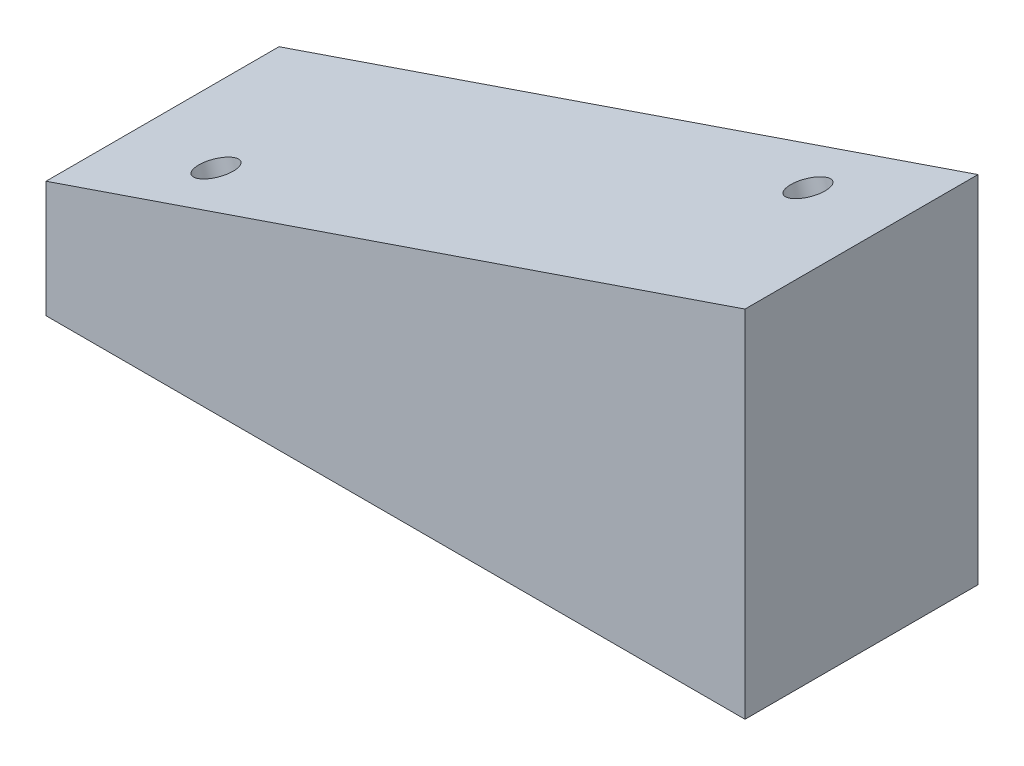
from build123d import *

# Parameters (mm, degrees)
BOSS_EXTRUDE1_DEPTH         = 50.8
F_3_8_16_TAPPED_HOLE1_D     = 7.9375
F_3_8_16_TAPPED_HOLE1_DEPTH = 25.4
F_3_8_16_TAPPED_HOLE1_TIP   = 2.384665582
F_3_8_16_TAPPED_HOLE2_D     = 7.9375
F_3_8_16_TAPPED_HOLE2_DEPTH = 25.4
F_3_8_16_TAPPED_HOLE2_TIP   = 2.384665582


with BuildPart() as part:
    # Sketch1 → Boss-Extrude1 (new body)
    with BuildSketch(Plane.XY):
        Polygon((-76.2, 0), (76.2, 0), (76.2, 77.459343803), (-76.2, 25.4), align=None)
    extrude(amount=-BOSS_EXTRUDE1_DEPTH)

    # 3/8-16 Tapped Hole1
    with Locations(Plane(origin=(-15.732418717, 46.055528891, 0), x_dir=(0.946311265, 0.323256847, 0), z_dir=(-0.323256847, 0.946311265, 0))):
        with Locations((-38.143756412, 12.7), (71.393743588, 38.1)):
            Hole(F_3_8_16_TAPPED_HOLE1_D / 2, depth=F_3_8_16_TAPPED_HOLE1_DEPTH)
            with Locations((0, 0, -(F_3_8_16_TAPPED_HOLE1_DEPTH + F_3_8_16_TAPPED_HOLE1_TIP / 2))):  # 118° drill point
                Cone(0, F_3_8_16_TAPPED_HOLE1_D / 2, F_3_8_16_TAPPED_HOLE1_TIP, mode=Mode.SUBTRACT)

    # 3/8-16 Tapped Hole2
    with Locations(Plane(origin=(0, 0, 0), x_dir=(-1, 0, 0), z_dir=(0, -1, 0))):
        with Locations((38.1, 25.4), (-38.1, 25.4)):
            Hole(F_3_8_16_TAPPED_HOLE2_D / 2, depth=F_3_8_16_TAPPED_HOLE2_DEPTH)
            with Locations((0, 0, -(F_3_8_16_TAPPED_HOLE2_DEPTH + F_3_8_16_TAPPED_HOLE2_TIP / 2))):  # 118° drill point
                Cone(0, F_3_8_16_TAPPED_HOLE2_D / 2, F_3_8_16_TAPPED_HOLE2_TIP, mode=Mode.SUBTRACT)


solid = part.part
